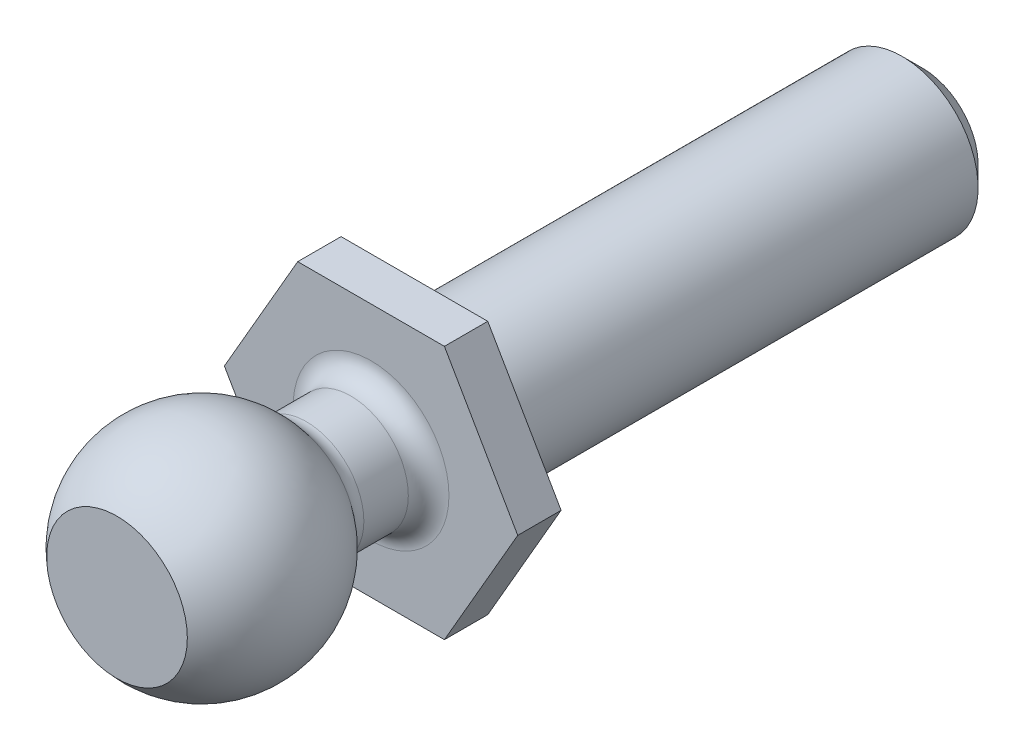
from build123d import *

# Parameters (mm, degrees)
BOSS_EXTRUDE1_DEPTH = 0.8128
SKETCH2_R           = 1.0795
BOSS_EXTRUDE2_DEPTH = 3.175
FILLET1_R           = 0.381
SKETCH4_R           = 1.4224
BOSS_EXTRUDE3_DEPTH = 9.525
CHAMFER1_SIZE       = 0.381


with BuildPart() as part:
    # Sketch1 → Boss-Extrude1 (new body)
    with BuildSketch(Plane.XY):
        Polygon((2.749630657, 0), (1.374815329, 2.38125), (-1.374815329, 2.38125), (-2.749630657, 0), (-1.374815329, -2.38125), (1.374815329, -2.38125), align=None)
    extrude(amount=BOSS_EXTRUDE1_DEPTH)

    # Sketch2 → Boss-Extrude2 (add)
    with BuildSketch(Plane.XY.offset(0.8128)):
        Circle(SKETCH2_R)
    extrude(amount=BOSS_EXTRUDE2_DEPTH)

    # Sketch3 one side → Revolve2 (revolve)
    with BuildSketch(Plane.XY.offset(3.9878)):
        with BuildLine():
            Line((0, 1.0795), (0, 2.06375))
            ThreePointArc((0, 2.06375), (-2.06375, 0), (0, -2.06375))
            Line((0, -2.06375), (0, -1.0795))
            ThreePointArc((0, -1.0795), (-1.0795, 0), (0, 1.0795))
        make_face()
    revolve(axis=Axis((0, 2.06375, 3.9878), (0, -1, 0)))

    # Fillet1
    fillet1_edges = [part.edges().sort_by_distance(p)[0] for p in [
        (-1.0795, 0, 0.8128),
        (-1.0795, 0, 2.228895849),
    ]]
    fillet(fillet1_edges, radius=FILLET1_R)

    # Sketch4 → Boss-Extrude3 (add)
    with BuildSketch(Plane(origin=(0, 0, 0), x_dir=(-1, 0, 0), z_dir=(0, 0, -1))):
        Circle(SKETCH4_R)
    extrude(amount=BOSS_EXTRUDE3_DEPTH)

    # Chamfer1
    chamfer1_edges = [part.edges().sort_by_distance(p)[0] for p in [
        (1.4224, 0, -9.525),
    ]]
    chamfer(chamfer1_edges, length=CHAMFER1_SIZE)

    # Split1
    split(bisect_by=Plane.XY.offset(5.5753), keep=Keep.BOTTOM)


solid = part.part
